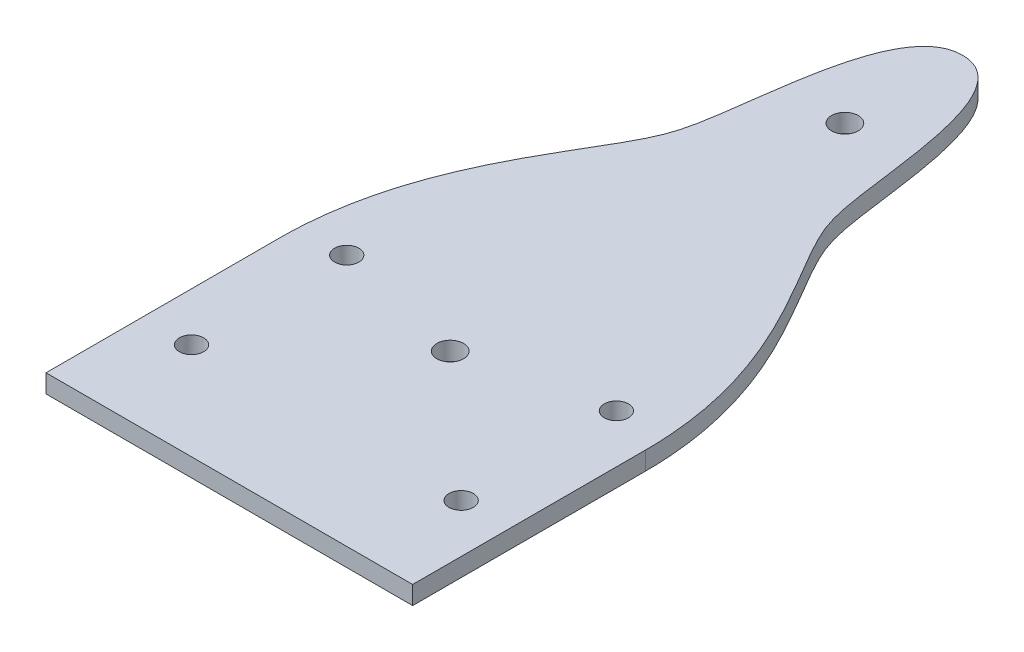
from build123d import *

# Parameters (mm, degrees)
SKETCH1_W           = 60
SKETCH1_H           = 120
BOSS_EXTRUDE1_DEPTH = 3
SKETCH2_R           = 2.185
CUT_EXTRUDE1_DEPTH  = 4
CUT_EXTRUDE2_DEPTH  = 4
SKETCH4_R           = 1.984375
CUT_EXTRUDE3_DEPTH  = 4.0000001


with BuildPart() as part:
    # Sketch1 → Boss-Extrude1 (new body)
    with BuildSketch(Plane(origin=(0, 0, 0), x_dir=(1, 0, 0), z_dir=(0, 1, 0))):
        Rectangle(SKETCH1_W, SKETCH1_H)
    extrude(amount=BOSS_EXTRUDE1_DEPTH)

    # Sketch2 → Cut-Extrude1 (cut, through all)
    with BuildSketch(Plane(origin=(0, 3, 0), x_dir=(1, 0, 0), z_dir=(0, 1, 0))):
        with Locations((0, -23.856)):
            Circle(SKETCH2_R)
        with Locations((0, 40.736)):
            Circle(SKETCH2_R)
    extrude(amount=-CUT_EXTRUDE1_DEPTH, mode=Mode.SUBTRACT)

    # Sketch3 → Cut-Extrude2 (cut, through all)
    with BuildSketch(Plane(origin=(0, 3, 0), x_dir=(1, 0, 0), z_dir=(0, 1, 0))):
        with BuildLine():
            Line((30, -21.9), (30, 60))
            Line((30, 60), (0, 60))
            add(Edge.make_bspline(
                [(0, 60), (9.906897678, 60), (10.116738443, 32.51403174), (16.216386116, 16.253262419), (30, -0.686105814), (30, -21.9)],
                knots=[0, 0, 0, 0, 0.419462523, 0.519462523, 1, 1, 1, 1], degree=3))
        make_face()
    cut_extrude2 = extrude(amount=-CUT_EXTRUDE2_DEPTH, mode=Mode.SUBTRACT)

    # Mirror1: Cut-Extrude2 across plane
    add(cut_extrude2.mirror(Plane(origin=(0, 0, 0), x_dir=(0, 0, 1), z_dir=(1, 0, 0))), mode=Mode.SUBTRACT)

    # Sketch4 → Cut-Extrude3 (cut, through all)
    with BuildSketch(Plane(origin=(0, 3, 0), x_dir=(1, 0, 0), z_dir=(0, 1, 0))):
        with Locations((22.0625, -44.125)):
            Circle(SKETCH4_R)
        with Locations((22.0625, -18.725)):
            Circle(SKETCH4_R)
        with Locations((-22.0625, -18.725)):
            Circle(SKETCH4_R)
        with Locations((-22.0625, -44.125)):
            Circle(SKETCH4_R)
    extrude(amount=-CUT_EXTRUDE3_DEPTH, mode=Mode.SUBTRACT)


solid = part.part
